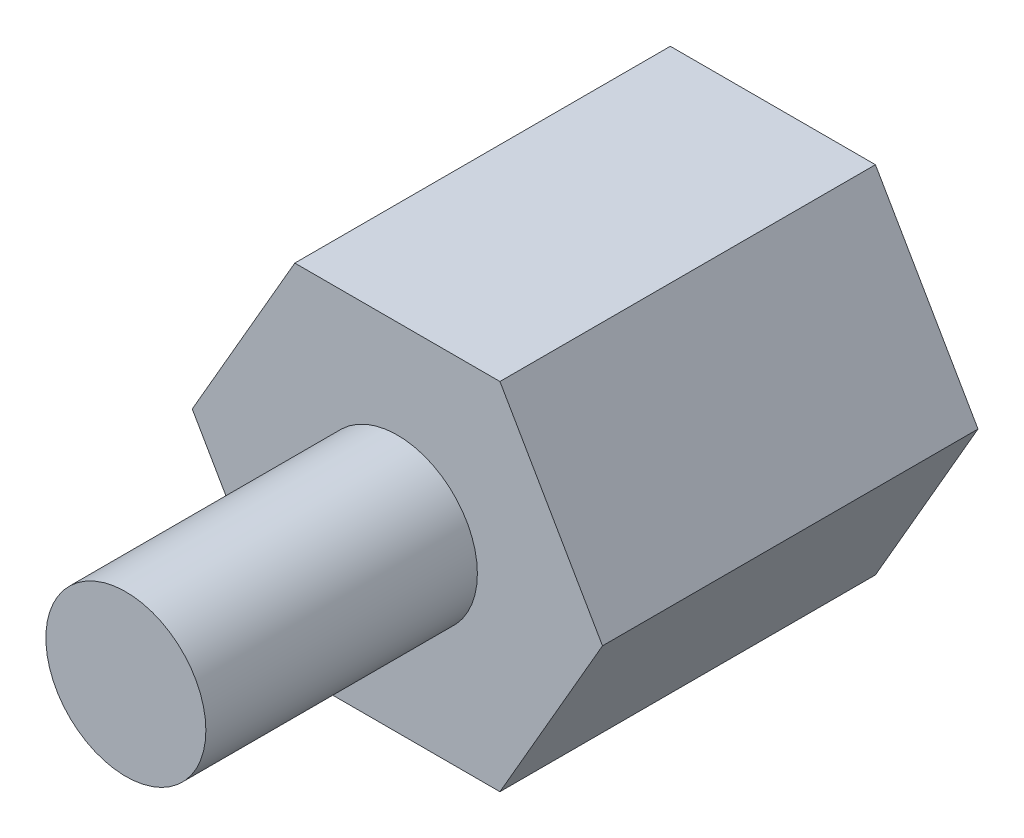
from build123d import *

# Parameters (mm, degrees)
BOSS_EXTRU_1_DEPTH      = 6.5
ESQUISSE2_R             = 1.385
BOSS_EXTRU_2_DEPTH      = 4.7
ESQUISSE3_R             = 1.35
ENL_V_MAT_EXTRU_1_DEPTH = 4.7


with BuildPart() as part:
    # Esquisse1 → Boss.-Extru.1 (new body)
    with BuildSketch(Plane.XY):
        Polygon((3.550704156, 0), (1.775352078, 3.075), (-1.775352078, 3.075), (-3.550704156, 0), (-1.775352078, -3.075), (1.775352078, -3.075), align=None)
    extrude(amount=BOSS_EXTRU_1_DEPTH)

    # Esquisse2 → Boss.-Extru.2 (add)
    with BuildSketch(Plane.XY.offset(6.5)):
        Circle(ESQUISSE2_R)
    extrude(amount=BOSS_EXTRU_2_DEPTH)

    # Esquisse3 → Enlèv. mat.-Extru.1 (cut)
    with BuildSketch(Plane(origin=(0, 0, 0), x_dir=(-1, 0, 0), z_dir=(0, 0, -1))):
        Circle(ESQUISSE3_R)
    extrude(amount=-ENL_V_MAT_EXTRU_1_DEPTH, mode=Mode.SUBTRACT)


solid = part.part
